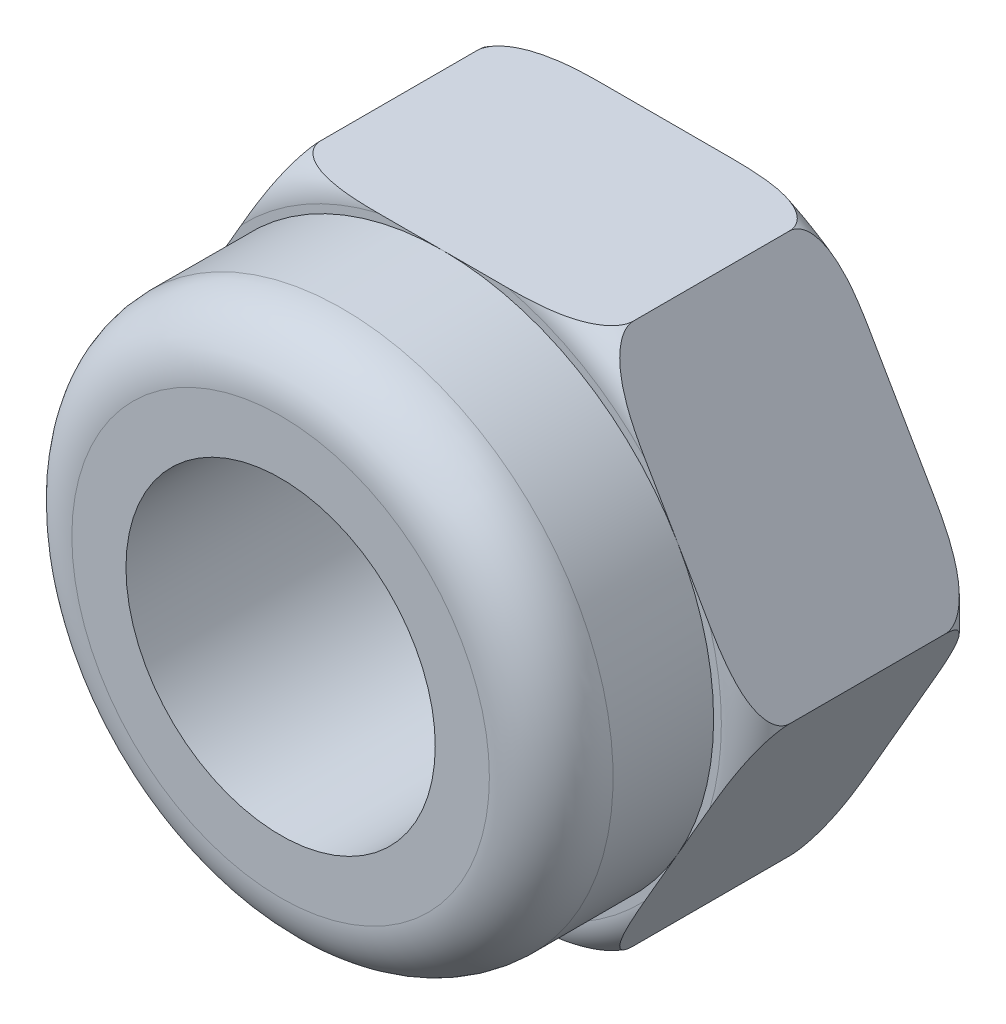
from build123d import *

# Parameters (mm, degrees)
SZKIC1_R                    = 2
DODANIE_WYCI_GNI_CIE1_DEPTH = 2.9
SZKIC2_R                    = 3.5
SZKIC2_R_2                  = 2
DODANIE_WYCI_GNI_CIE2_DEPTH = 5


with BuildPart() as part:
    # Szkic1 → Dodanie-wyciągnięcie1 (new body)
    with BuildSketch(Plane.XY):
        Polygon((-4.041451884, 0), (-2.020725942, -3.5), (2.020725942, -3.5), (4.041451884, 0), (2.020725942, 3.5), (-2.020725942, 3.5), align=None)
        Circle(SZKIC1_R, mode=Mode.SUBTRACT)
    extrude(amount=DODANIE_WYCI_GNI_CIE1_DEPTH)

    # Szkic2 → Dodanie-wyciągnięcie2 (add)
    with BuildSketch(Plane.XY):
        Circle(SZKIC2_R)
        Circle(SZKIC2_R_2, mode=Mode.SUBTRACT)
    extrude(amount=DODANIE_WYCI_GNI_CIE2_DEPTH)

    # Szkic3 → Wycięcie-obrót1 (revolve, cut)
    with BuildSketch(Plane(origin=(0, 0, 0), x_dir=(1, 0, 0), z_dir=(0, 1, 0))):
        with BuildLine():
            Line((-4.041451884, 0), (-4.041451884, -0.441451884))
            ThreePointArc((-4.041451884, -0.441451884), (-3.912153621, -0.129298263), (-3.6, 0))
            Line((-3.6, 0), (-4.041451884, 0))
        make_face()
        with BuildLine():
            ThreePointArc((-3.6, -2.9), (-3.912153621, -2.770701737), (-4.041451884, -2.458548116))
            Line((-4.041451884, -2.458548116), (-4.041451884, -2.9))
            Line((-4.041451884, -2.9), (-3.6, -2.9))
        make_face()
        with BuildLine():
            Line((-3.5, -5), (-2.7, -5))
            ThreePointArc((-2.7, -5), (-3.265685425, -4.765685425), (-3.5, -4.2))
            Line((-3.5, -4.2), (-3.5, -5))
        make_face()
    revolve(axis=Axis((0, 0, -1.701574894), (0, 0, 1)), mode=Mode.SUBTRACT)


solid = part.part
